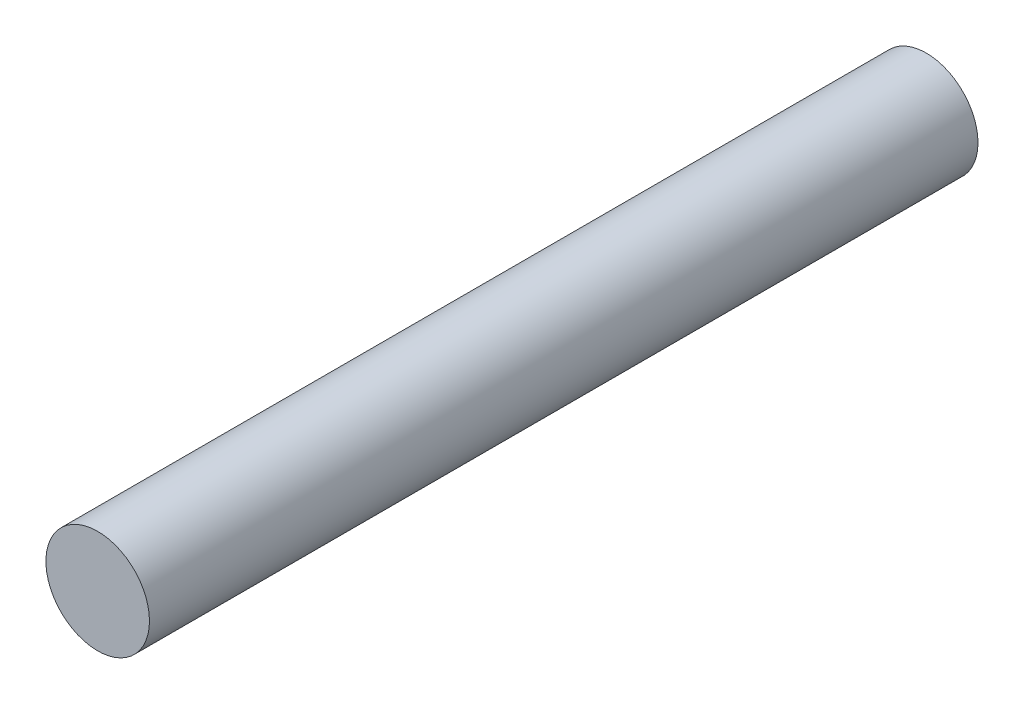
from build123d import *

# Parameters (mm, degrees)
SKETCH1_R           = 3.175
BOSS_EXTRUDE1_DEPTH = 25.4


with BuildPart() as part:
    # Sketch1 → Boss-Extrude1 (new body, symmetric)
    with BuildSketch(Plane.XY):
        Circle(SKETCH1_R)
    extrude(amount=BOSS_EXTRUDE1_DEPTH, both=True)


solid = part.part
